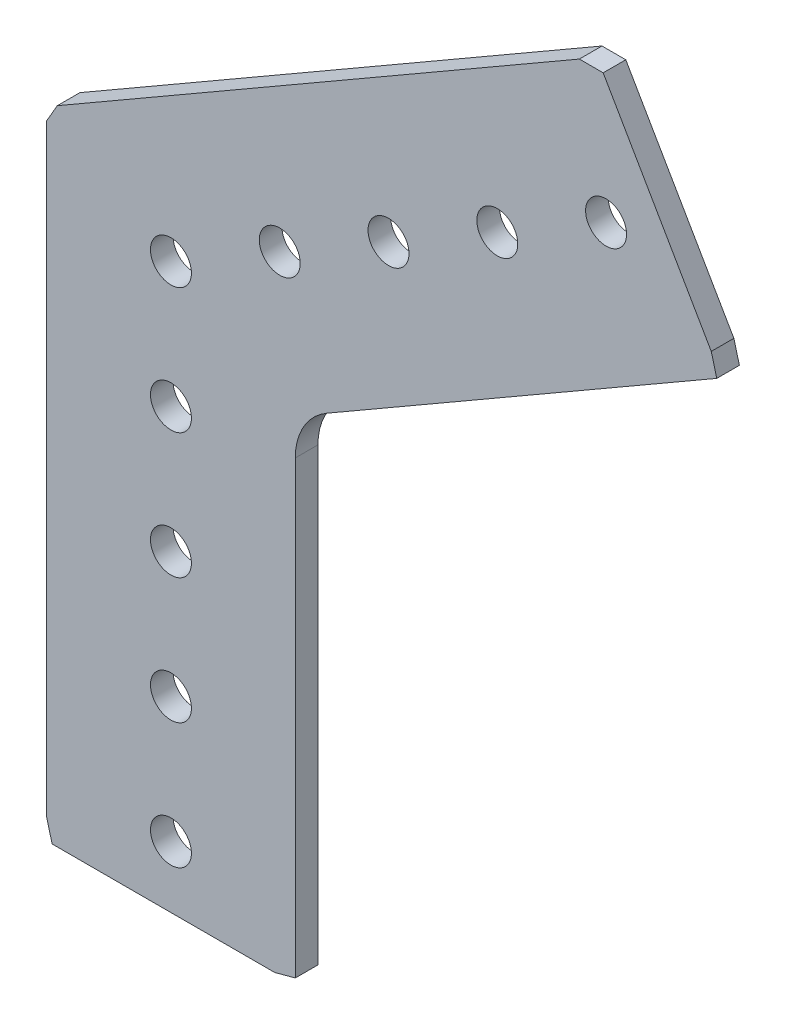
from build123d import *

# Parameters (mm, degrees)
SKETCH1_R           = 2.0701
BOSS_EXTRUDE1_DEPTH = 2.286


with BuildPart() as part:
    # Sketch1 → Boss-Extrude1 (new body)
    with BuildSketch(Plane.XY.offset(2.286)):
        with BuildLine():
            Line((41.2908279, 38.357320472), (-11.4935, 7.88227455))
            Line((-11.4935, 7.88227455), (-12.573, 6.012525703))
            Line((-12.573, 6.012525703), (-12.573, -54.937566141))
            Line((-12.573, -54.937566141), (-12.014209682, -57.023))
            Line((-12.014209682, -57.023), (10.487566141, -57.023))
            Line((10.487566141, -57.023), (12.573, -56.464209682))
            Line((12.573, -56.464209682), (12.573, -10.925199144))
            ThreePointArc((12.573, -10.925199144), (13.423738686, -7.750199144), (15.748, -5.42593783))
            Line((15.748, -5.42593783), (55.185939989, 17.343567439))
            Line((55.185939989, 17.343567439), (54.627149671, 19.429001298))
            Line((54.627149671, 19.429001298), (43.6988795, 38.357320472))
            Line((43.6988795, 38.357320472), (41.2908279, 38.357320472))
        make_face()
        Circle(SKETCH1_R, mode=Mode.SUBTRACT)
        with Locations((0, -38.1)):
            Circle(SKETCH1_R, mode=Mode.SUBTRACT)
        with Locations((0, -12.7)):
            Circle(SKETCH1_R, mode=Mode.SUBTRACT)
        with Locations((0, -25.4)):
            Circle(SKETCH1_R, mode=Mode.SUBTRACT)
        with Locations((0, -50.8)):
            Circle(SKETCH1_R, mode=Mode.SUBTRACT)
        with Locations((32.995567884, 19.05)):
            Circle(SKETCH1_R, mode=Mode.SUBTRACT)
        with Locations((10.998522628, 6.35)):
            Circle(SKETCH1_R, mode=Mode.SUBTRACT)
        with Locations((21.997045256, 12.7)):
            Circle(SKETCH1_R, mode=Mode.SUBTRACT)
        with Locations((43.994090512, 25.4)):
            Circle(SKETCH1_R, mode=Mode.SUBTRACT)
    extrude(amount=-BOSS_EXTRUDE1_DEPTH)


solid = part.part
